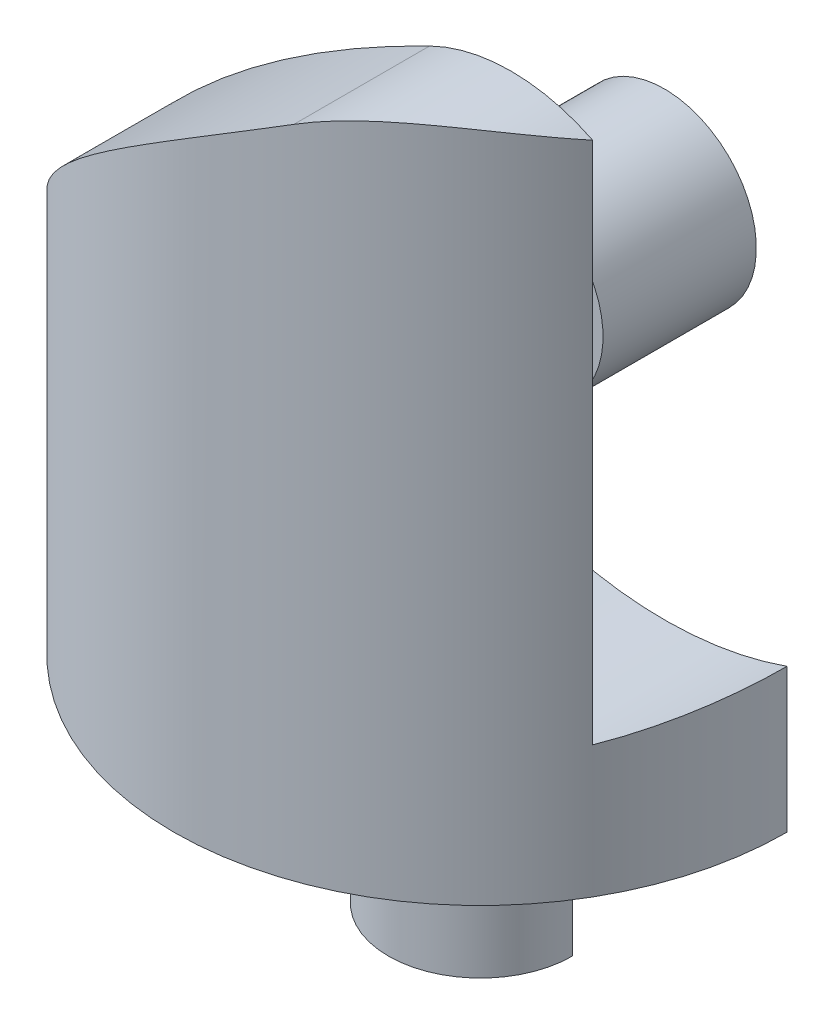
from build123d import *

# Parameters (mm, degrees)
SKETCH1_R               = 5
BOSS_EXTRUDE1_DEPTH     = 13
CUT_EXTRUDE1_DEPTH      = 6
CUT_EXTRUDE1_DEPTH_BACK = 6
CUT_EXTRUDE5_DEPTH      = 12.000000091
CUT_EXTRUDE5_DEPTH_BACK = 1.0000001
CUT_EXTRUDE6_DEPTH      = 2.5
SKETCH6_R               = 1.5
BOSS_EXTRUDE2_DEPTH     = 2.5
BOSS_EXTRUDE3_DEPTH     = 3.5
SKETCH8_R               = 6
SKETCH8_R_2             = 1.5
CUT_EXTRUDE8_DEPTH      = 2.5


with BuildPart() as part:
    # Sketch1 → Boss-Extrude1 (new body)
    with BuildSketch(Plane(origin=(0, 0, 0), x_dir=(1, 0, 0), z_dir=(0, 1, 0))):
        Circle(SKETCH1_R)
    extrude(amount=BOSS_EXTRUDE1_DEPTH)

    # Sketch2 → Cut-Extrude1 (cut, two sides)
    with BuildSketch(Plane.XY) as cut_extrude1_sk:
        with BuildLine():
            Line((3, 13), (0, 13))
            Line((0, 13), (-5, 13))
            Line((-5, 13), (-5, 3))
            add(Edge.make_bspline(
                [(-5, 3), (-4.520998695, 6.032498319), (-1.99103132, 8.299343225)],
                knots=[0.227620842, 0.227620842, 0.227620842, 0.714929142, 0.714929142, 0.714929142], degree=2))
            ThreePointArc((-1.99103132, 8.299343225), (-0.428066793, 11.6398294), (3, 13))
        make_face()
        with BuildLine():
            Line((3, 11), (3, 13))
            ThreePointArc((3, 13), (-0.428066793, 11.6398294), (-1.99103132, 8.299343225))
            add(Edge.make_bspline(
                [(-1.99103132, 8.299343225), (-0.511023752, 9.625426577), (1.670853534, 10.689492456)],
                knots=[0.714929142, 0.714929142, 0.714929142, 1, 1, 1], degree=2))
            ThreePointArc((1.670853534, 10.689492456), (2.317532919, 10.921341932), (3, 11))
        make_face()
        with BuildLine():
            ThreePointArc((5, 12.582575695), (4.021548218, 12.894531565), (3, 13))
            Line((3, 13), (3, 11))
            ThreePointArc((3, 11), (4.070466269, 10.802517077), (5, 10.236067977))
            Line((5, 10.236067977), (5, 12.582575695))
        make_face()
        with BuildLine():
            ThreePointArc((8, 8), (7.183300133, 10.738612788), (5, 12.582575695))
            Line((5, 12.582575695), (5, 10.236067977))
            ThreePointArc((5, 10.236067977), (5.738612788, 9.224744871), (6, 8))
            ThreePointArc((6, 8), (5.9642797, 7.538431086), (5.857969425, 7.08785376))
            ThreePointArc((5.857969425, 7.08785376), (5.845570523, 7.049879797), (5.832667083, 7.012074296))
            add(Edge.make_bspline(
                [(5.04344694, 3.436632318), (5.24663774, 5.244224617), (5.832667083, 7.012074296)],
                knots=[0.479473452, 0.479473452, 0.479473452, 0.989075242, 0.989075242, 0.989075242], degree=2))
            ThreePointArc((5.04344694, 3.436632318), (7.196262307, 5.28129026), (8, 8))
        make_face()
        with BuildLine():
            Line((5, 5.763932023), (5, 3.417424305))
            ThreePointArc((5, 3.417424305), (5.021746281, 3.426976714), (5.04344694, 3.436632318))
            add(Edge.make_bspline(
                [(5.04344694, 3.436632318), (5.24663774, 5.244224617), (5.832667083, 7.012074296)],
                knots=[0.479473452, 0.479473452, 0.479473452, 0.989075242, 0.989075242, 0.989075242], degree=2))
            ThreePointArc((5.832667083, 7.012074296), (5.495622681, 6.335107381), (5, 5.763932023))
        make_face()
        with BuildLine():
            Line((5, 13), (3, 13))
            ThreePointArc((3, 13), (4.021548218, 12.894531565), (5, 12.582575695))
            Line((5, 12.582575695), (5, 13))
        make_face()
    extrude(amount=CUT_EXTRUDE1_DEPTH, mode=Mode.SUBTRACT)
    extrude(cut_extrude1_sk.sketch, amount=-CUT_EXTRUDE1_DEPTH_BACK, mode=Mode.SUBTRACT)

    # Sketch4 → Cut-Extrude5 (cut, two sides)
    with BuildSketch(Plane(origin=(0, 0, 0), x_dir=(1, 0, 0), z_dir=(0, 1, 0))) as cut_extrude5_sk:
        Polygon((0, 0), (-5.690111437, 0), (-5.690111437, 7.683278955), (11.026883972, 8.496072863), (8.601615285, 0), align=None)
    extrude(amount=CUT_EXTRUDE5_DEPTH, mode=Mode.SUBTRACT)
    extrude(cut_extrude5_sk.sketch, amount=-CUT_EXTRUDE5_DEPTH_BACK, mode=Mode.SUBTRACT)

    # Sketch5 → Cut-Extrude6 (cut)
    with BuildSketch(Plane(origin=(0, 0, 0), x_dir=(-1, 0, 0), z_dir=(0, 0, -1))):
        Polygon((0, 3), (-6.67084339, 3), (-6.67084339, 14.94999742), (5.657152112, 14.94999742), (5.977359788, 3), align=None)
    extrude(amount=-CUT_EXTRUDE6_DEPTH, mode=Mode.SUBTRACT)

    # Sketch7 → Boss-Extrude3 (add)
    with BuildSketch(Plane.XZ):
        with BuildLine():
            ThreePointArc((1.5, 0), (0, 1.5), (-1.5, 0))
            Line((-1.5, 0), (1.5, 0))
        make_face()
    extrude(amount=BOSS_EXTRUDE3_DEPTH)

    # Sketch8 → Cut-Extrude8 (cut)
    with BuildSketch(Plane(origin=(0, 0, 0), x_dir=(-1, 0, 0), z_dir=(0, 0, -1))):
        with Locations((-3, 8)):
            Circle(SKETCH8_R)
        with Locations((-3, 8)):
            Circle(SKETCH8_R_2, mode=Mode.SUBTRACT)
    extrude(amount=-CUT_EXTRUDE8_DEPTH, mode=Mode.SUBTRACT)


with BuildPart() as body_2:
    # Sketch6 → Boss-Extrude2 (new body)
    with BuildSketch(Plane(origin=(0, 0, 0), x_dir=(-1, 0, 0), z_dir=(0, 0, -1))):
        with Locations((-3, 8)):
            Circle(SKETCH6_R)
    extrude(amount=-BOSS_EXTRUDE2_DEPTH)


solid = Compound([part.part, body_2.part])
